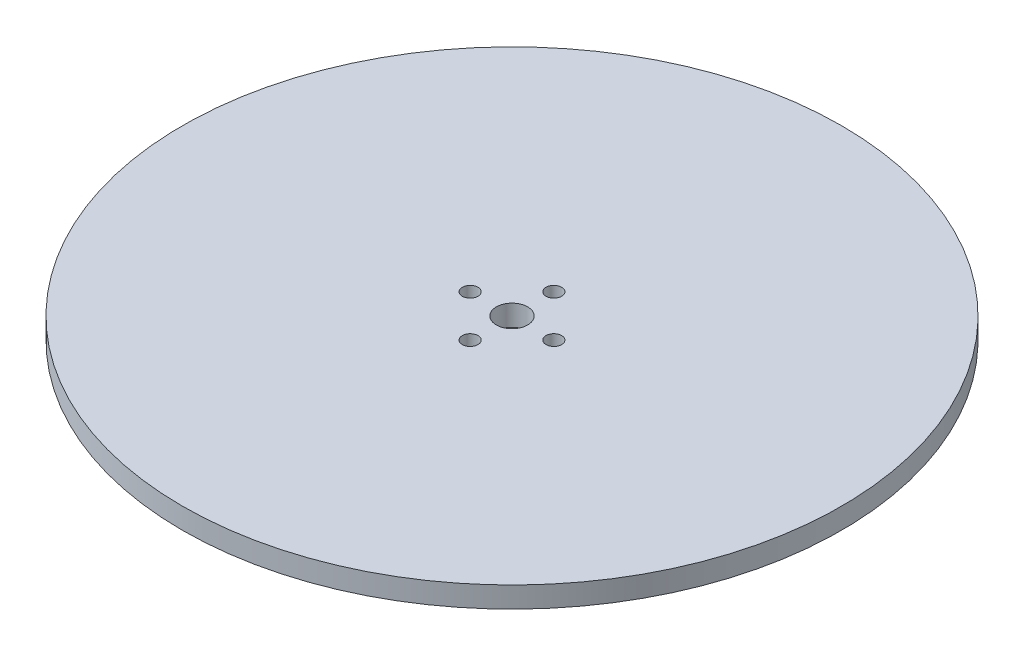
from build123d import *

# Parameters (mm, degrees)
SKETCH_1_R          = 63
EXTRUDE_1_DEPTH     = 4
SKETCH_2_R          = 1.5
SKETCH_2_R_2        = 3
CUT_EXTRUDE_1_DEPTH = 5


with BuildPart() as part:
    # 草图1 → 凸台-拉伸1 (new body)
    with BuildSketch(Plane(origin=(0, 0, 0), x_dir=(1, 0, 0), z_dir=(0, 1, 0))):
        Circle(SKETCH_1_R)
    extrude(amount=EXTRUDE_1_DEPTH)

    # 草图2 → 切除-拉伸1 (cut, through all)
    with BuildSketch(Plane(origin=(0, 4, 0), x_dir=(1, 0, 0), z_dir=(0, 1, 0))):
        with Locations((8, 0)):
            Circle(SKETCH_2_R)
        with Locations((0, 8)):
            Circle(SKETCH_2_R)
        with Locations((-8, 0)):
            Circle(SKETCH_2_R)
        with Locations((0, -8)):
            Circle(SKETCH_2_R)
        Circle(SKETCH_2_R_2)
    extrude(amount=-CUT_EXTRUDE_1_DEPTH, mode=Mode.SUBTRACT)


solid = part.part
